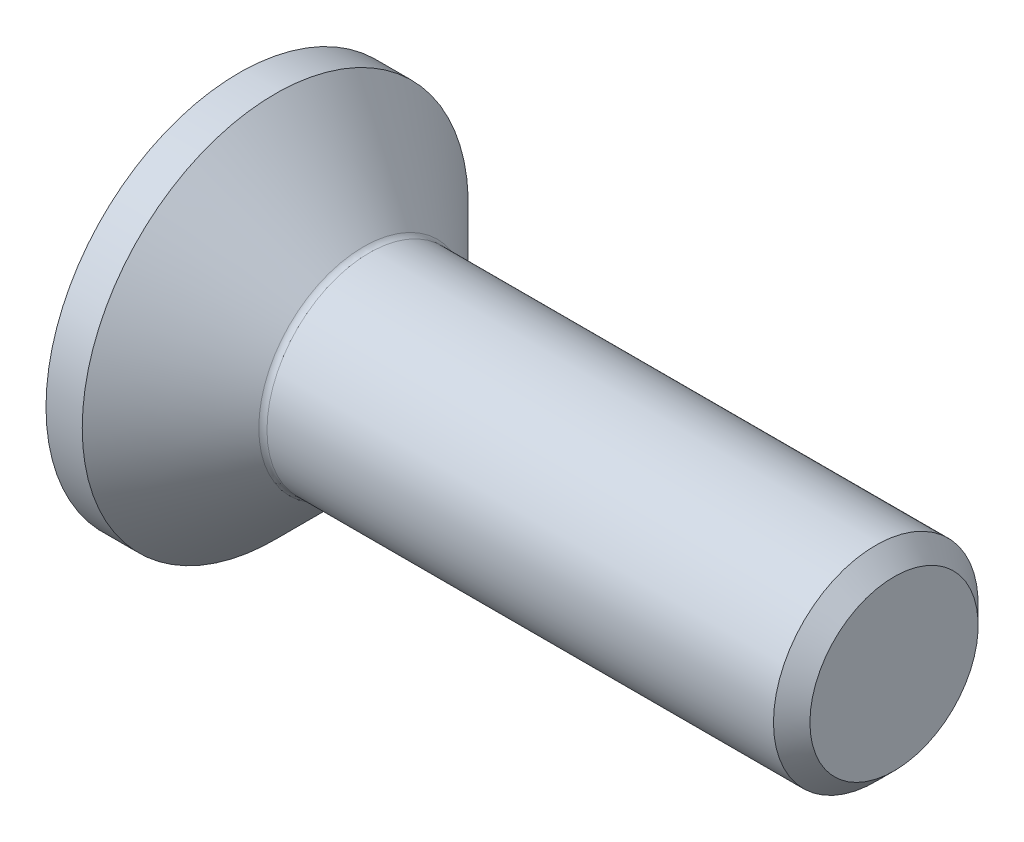
from build123d import *

# Parameters (mm, degrees)
FILLET1_R   = 0.2
HEX_2_DEPTH = 1.9


with BuildPart() as part:
    # BodySke → BaseBody (revolve)
    with BuildSketch(Plane.XY):
        Polygon((0, 0), (0, 4.715), (0.885, 4.715), (3.1, 2.5), (15.555, 2.5), (16, 2.055), (16, 0), align=None)
    revolve(axis=Axis((0, 0, 0), (1, 0, 0)))

    # Fillet1
    fillet1_edges = [part.edges().sort_by_distance(p)[0] for p in [
        (3.1, -2.5, 0),
    ]]
    fillet(fillet1_edges, radius=FILLET1_R)

    # Sketch2 → PreBroach (revolve, cut)
    with BuildSketch(Plane.XY):
        Polygon((0, 1.5), (1.9, 1.5), (2.766025404, 0), (0, 0), align=None)
    revolve(axis=Axis((0, 0, 0), (1, 0, 0)), mode=Mode.SUBTRACT)

    # Sketch3 → Hex 2 (cut)
    with BuildSketch(Plane.ZY):
        Polygon((-1.5, -0.866025404), (-1.5, 0.866025404), (0, 1.732050808), (1.5, 0.866025404), (1.5, -0.866025404), (0, -1.732050808), align=None)
    extrude(amount=-HEX_2_DEPTH, mode=Mode.SUBTRACT)


solid = part.part
